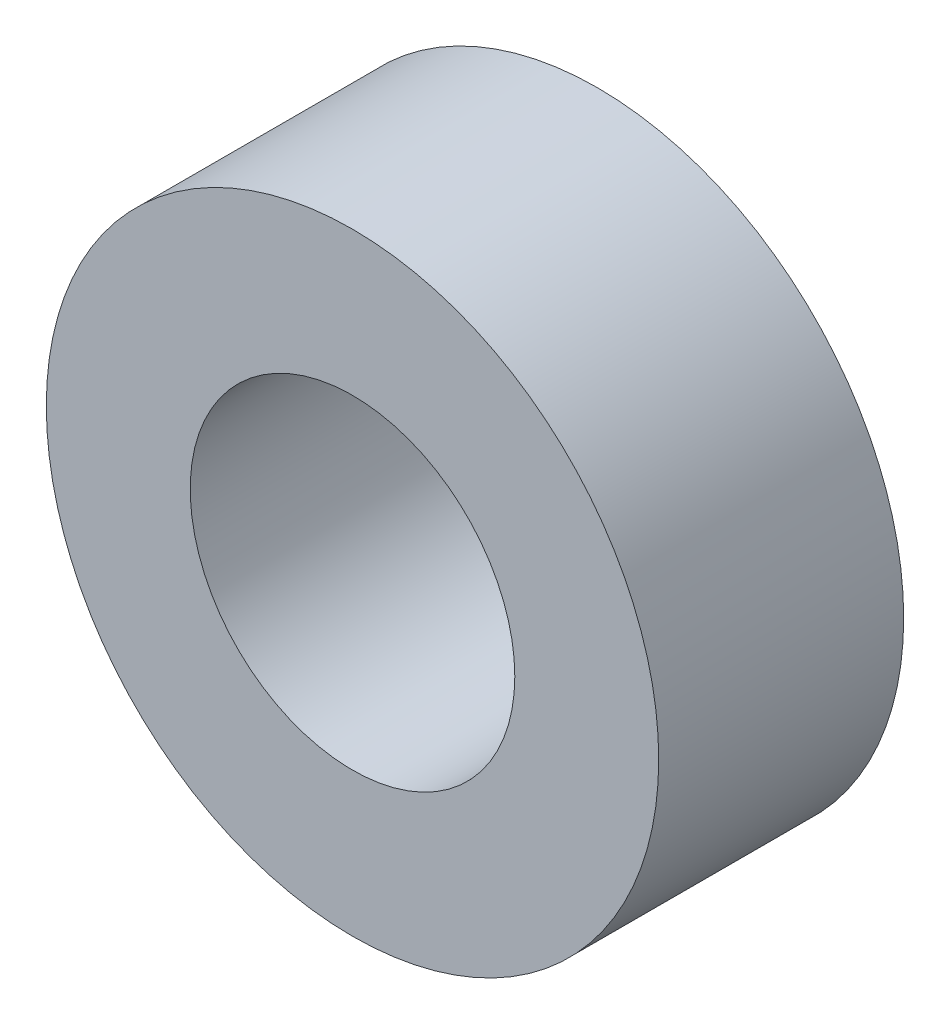
from build123d import *

# Parameters (mm, degrees)
SKETCH1_R      = 5
SKETCH1_R_2    = 2.65
EXTRUDE1_DEPTH = 2


with BuildPart() as part:
    # Sketch1 → Extrude1 (new body, symmetric)
    with BuildSketch(Plane.XY):
        Circle(SKETCH1_R)
        Circle(SKETCH1_R_2, mode=Mode.SUBTRACT)
    extrude(amount=EXTRUDE1_DEPTH, both=True)


solid = part.part
